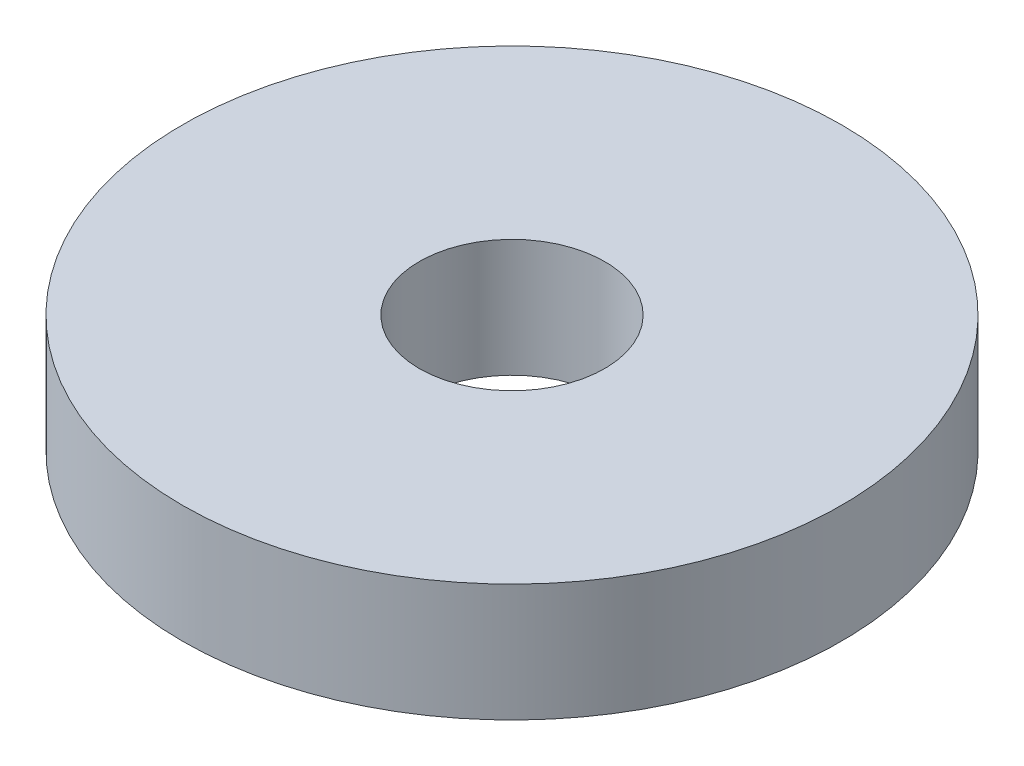
from build123d import *

# Parameters (mm, degrees)
SKETCH1_R           = 8.89
SKETCH1_R_2         = 2.5019
BOSS_EXTRUDE1_DEPTH = 3.175


with BuildPart() as part:
    # Sketch1 → Boss-Extrude1 (new body)
    with BuildSketch(Plane(origin=(0, 0, 0), x_dir=(1, 0, 0), z_dir=(0, 1, 0))):
        Circle(SKETCH1_R)
        Circle(SKETCH1_R_2, mode=Mode.SUBTRACT)
    extrude(amount=BOSS_EXTRUDE1_DEPTH)


solid = part.part
